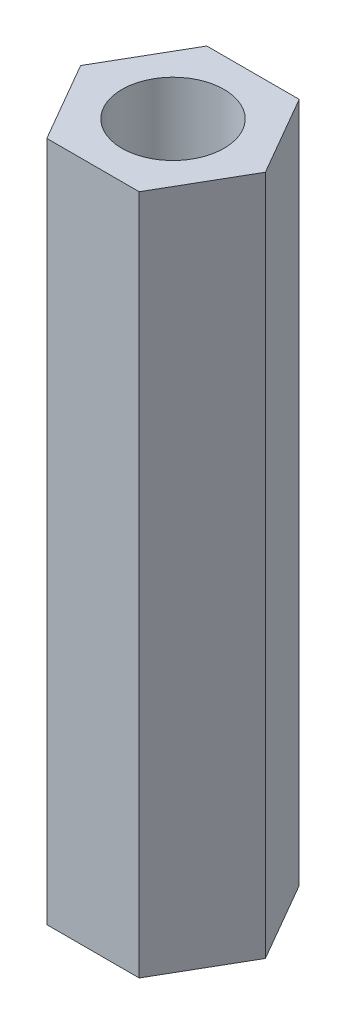
from build123d import *

# Parameters (mm, degrees)
SKETCH2_R           = 1.5
BOSS_EXTRUDE1_DEPTH = 20


with BuildPart() as part:
    # Sketch2 → Boss-Extrude1 (new body)
    with BuildSketch(Plane(origin=(0, 0, 0), x_dir=(1, 0, 0), z_dir=(0, 1, 0))):
        Polygon((2.713546265, 0), (1.356773133, 2.35), (-1.356773133, 2.35), (-2.713546265, 0), (-1.356773133, -2.35), (1.356773133, -2.35), align=None)
        Circle(SKETCH2_R, mode=Mode.SUBTRACT)
    extrude(amount=BOSS_EXTRUDE1_DEPTH)


solid = part.part
